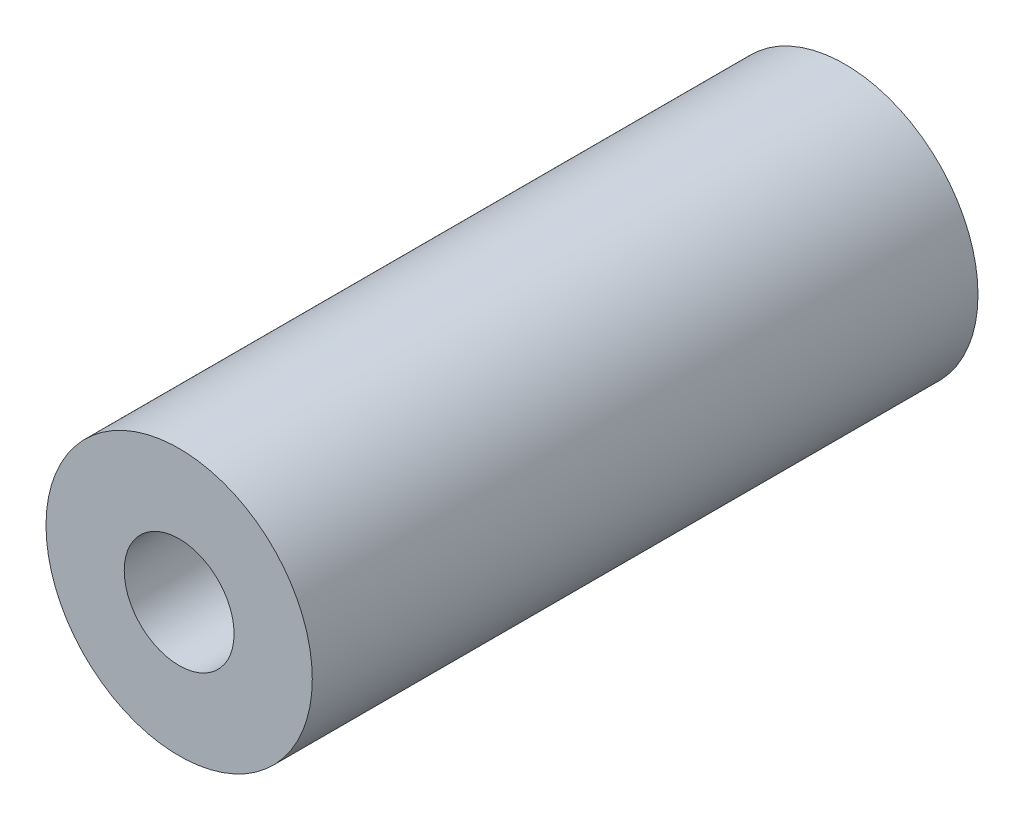
from build123d import *

# Parameters (mm, degrees)
SKETCH_1_R               = 4
SKETCH_1_R_2             = 1.25
EXTRUDE_1_DEPTH          = 10
M4X0_7_1_D               = 3.3
M4X0_7_1_DEPTH           = 11.5
M4X0_7_1_TIP             = 0.991420021
M4X0_7_1_ON_FACE_2_D     = 3.3
M4X0_7_1_ON_FACE_2_DEPTH = 11.5
M4X0_7_1_ON_FACE_2_TIP   = 0.991420021
M4X0_7_1_ON_FACE_3_D     = 3.3
M4X0_7_1_ON_FACE_3_DEPTH = 11.5
M4X0_7_1_ON_FACE_3_TIP   = 0.991420021


with BuildPart() as part:
    # ｽｹｯﾁ1 → ﾎﾞｽ - 押し出し1 (new body, symmetric)
    with BuildSketch(Plane.XY):
        Circle(SKETCH_1_R)
        Circle(SKETCH_1_R_2, mode=Mode.SUBTRACT)
        Circle(SKETCH_1_R_2)
    extrude(amount=EXTRUDE_1_DEPTH, both=True)

    # M4x0.7 ねじ穴1
    with Locations(Plane(origin=(0, 0, -10), x_dir=(0, -1, 0), z_dir=(0, 0, -1))):
        with Locations((0, 0)):
            Hole(M4X0_7_1_D / 2, depth=M4X0_7_1_DEPTH)
            with Locations((0, 0, -(M4X0_7_1_DEPTH + M4X0_7_1_TIP / 2))):  # 118° drill point
                Cone(0, M4X0_7_1_D / 2, M4X0_7_1_TIP, mode=Mode.SUBTRACT)

    # M4x0.7 ねじ穴1 on face 2
    with Locations(Plane(origin=(0, 0, 0), x_dir=(0, -1, 0), z_dir=(0, 0, -1))):
        with Locations((0, 0), (-3.399491027, 15.650266716), (-2.590821191, 13.66210105)):
            Hole(M4X0_7_1_ON_FACE_2_D / 2, depth=M4X0_7_1_ON_FACE_2_DEPTH)
            with Locations((0, 0, -(M4X0_7_1_ON_FACE_2_DEPTH + M4X0_7_1_ON_FACE_2_TIP / 2))):  # 118° drill point
                Cone(0, M4X0_7_1_ON_FACE_2_D / 2, M4X0_7_1_ON_FACE_2_TIP, mode=Mode.SUBTRACT)

    # M4x0.7 ねじ穴1 on face 3
    with Locations(Plane.XY.offset(10)):
        with Locations((0, 0)):
            Hole(M4X0_7_1_ON_FACE_3_D / 2, depth=M4X0_7_1_ON_FACE_3_DEPTH)
            with Locations((0, 0, -(M4X0_7_1_ON_FACE_3_DEPTH + M4X0_7_1_ON_FACE_3_TIP / 2))):  # 118° drill point
                Cone(0, M4X0_7_1_ON_FACE_3_D / 2, M4X0_7_1_ON_FACE_3_TIP, mode=Mode.SUBTRACT)


solid = part.part
